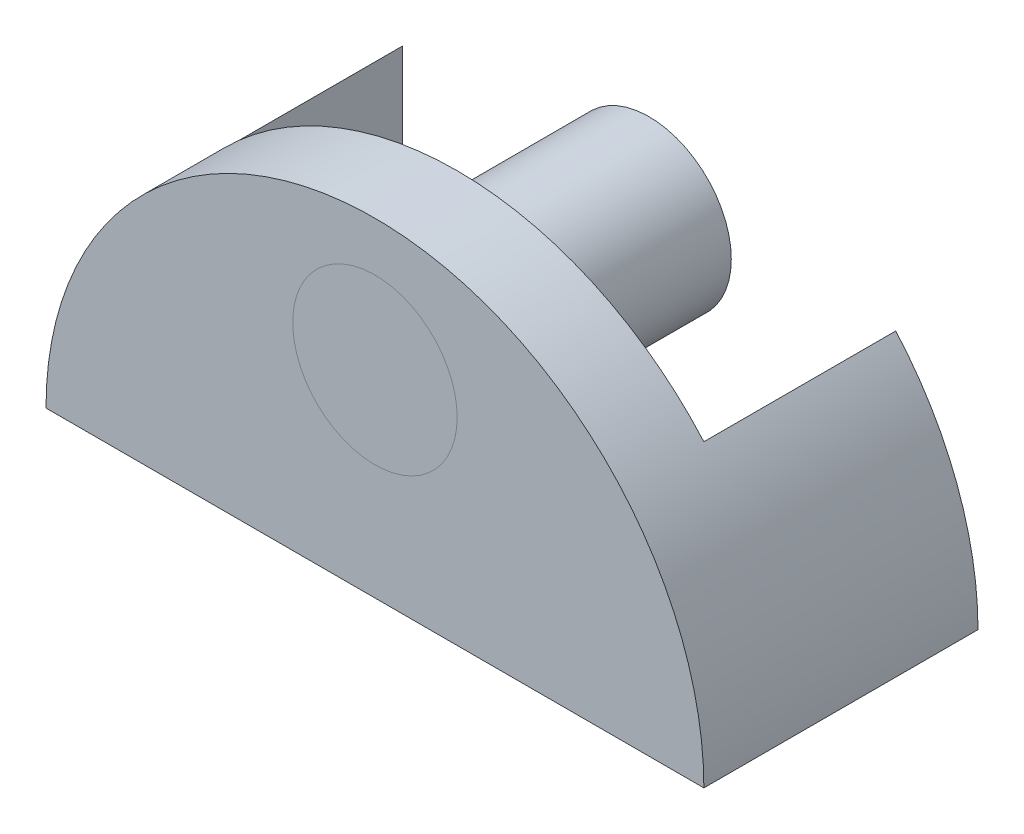
from build123d import *

# Parameters (mm, degrees)
BOSS_EXTRUDE1_DEPTH = 65
CUT_EXTRUDE1_START  = -60
SKETCH4_W           = 90
SKETCH4_H           = 35
CUT_EXTRUDE1_DEPTH  = 60
BOSS_EXTRUDE2_START = -50
SKETCH5_R           = 15
BOSS_EXTRUDE2_DEPTH = 50.000012
SKETCH7_W           = 120
SKETCH7_H           = 15
CUT_EXTRUDE3_DEPTH  = 61


with BuildPart() as part:
    # Sketch3 → Boss-Extrude1 (new body)
    with BuildSketch(Plane.XY):
        with BuildLine():
            Line((-60, 0), (60, 0))
            ThreePointArc((60, 0), (0, 60), (-60, 0))
        make_face()
    extrude(amount=BOSS_EXTRUDE1_DEPTH)

    # Sketch4 → Cut-Extrude1 (cut)
    with BuildSketch(Plane.XZ.offset(CUT_EXTRUDE1_START)):
        with Locations((0, 32.5)):
            Rectangle(SKETCH4_W, SKETCH4_H)
    extrude(amount=CUT_EXTRUDE1_DEPTH, mode=Mode.SUBTRACT)

    # Sketch5 → Boss-Extrude2 (add)
    with BuildSketch(Plane.XY.offset(65).offset(BOSS_EXTRUDE2_START)):
        with Locations((0, 36.035216542)):
            Circle(SKETCH5_R)
    extrude(amount=BOSS_EXTRUDE2_DEPTH)

    # Sketch7 → Cut-Extrude3 (cut, through all)
    with BuildSketch(Plane.XZ):
        with Locations((0, 7.5)):
            Rectangle(SKETCH7_W, SKETCH7_H)
    extrude(amount=-CUT_EXTRUDE3_DEPTH, mode=Mode.SUBTRACT)


solid = part.part
